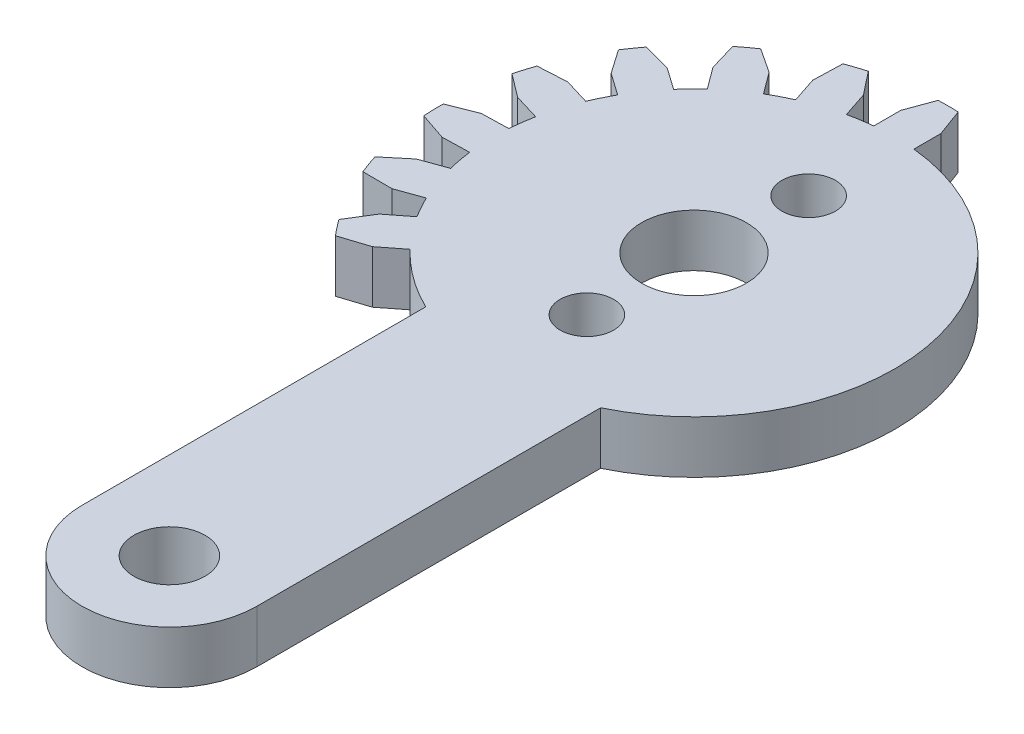
from build123d import *

# Parameters (mm, degrees)
CROQUIS1_R              = 2.034348523
CROQUIS1_R_2            = 3
SALIENTE_EXTRUIR1_DEPTH = 3
SALIENTE_EXTRUIR2_DEPTH = 3
MATRIZC1_COUNT          = 8
MATRIZC1_ANGLE          = 128
CROQUIS4_R              = 1.53
CORTAR_EXTRUIR1_DEPTH   = 10


with BuildPart() as part:
    # Croquis1 → Saliente-Extruir1 (new body)
    with BuildSketch(Plane(origin=(0, 0, 0), x_dir=(1, 0, 0), z_dir=(0, 1, 0))):
        with BuildLine():
            Line((-5, -10.339498295), (-5, -30))
            ThreePointArc((-5, -30), (0, -35), (5, -30))
            Line((5, -30), (5, -10.339498295))
            ThreePointArc((5, -10.339498295), (0, 11.485), (-5, -10.339498295))
        make_face()
        with Locations((0, -30)):
            Circle(CROQUIS1_R, mode=Mode.SUBTRACT)
        Circle(CROQUIS1_R_2, mode=Mode.SUBTRACT)
    extrude(amount=SALIENTE_EXTRUIR1_DEPTH)

    # Croquis3 → Saliente-Extruir2 (add)
    with BuildSketch(Plane(origin=(0, 0, 0), x_dir=(1, 0, 0), z_dir=(0, 1, 0))):
        with BuildLine():
            Line((-1.1484375, 12.965487086), (-1.1484375, 11.427436996))
            ThreePointArc((-1.1484375, 11.427436996), (0, 11.485), (1.1484375, 11.427436996))
            Line((1.1484375, 11.427436996), (1.1484375, 12.965487086))
            Line((1.1484375, 12.965487086), (0.57421875, 14.536162804))
            ThreePointArc((0.57421875, 14.536162804), (0, 14.5475), (-0.57421875, 14.536162804))
            Line((-0.57421875, 14.536162804), (-1.1484375, 12.965487086))
        make_face()
    saliente_extruir2 = extrude(amount=SALIENTE_EXTRUIR2_DEPTH)

    # MatrizC1: Saliente-Extruir2 ×8 about axis
    matrizc1_axis = Axis((0, 0, 0), (0, 1, 0))
    for i in range(1, MATRIZC1_COUNT):
        add(saliente_extruir2.rotate(matrizc1_axis, i * MATRIZC1_ANGLE / (MATRIZC1_COUNT - 1)))

    # Croquis4 → Cortar-Extruir1 (cut)
    with BuildSketch(Plane.XZ):
        with Locations((0.448059245, -6.108589683)):
            Circle(CROQUIS4_R)
        with Locations((0, 6.125)):
            Circle(CROQUIS4_R)
    extrude(amount=-CORTAR_EXTRUIR1_DEPTH, mode=Mode.SUBTRACT)


solid = part.part
